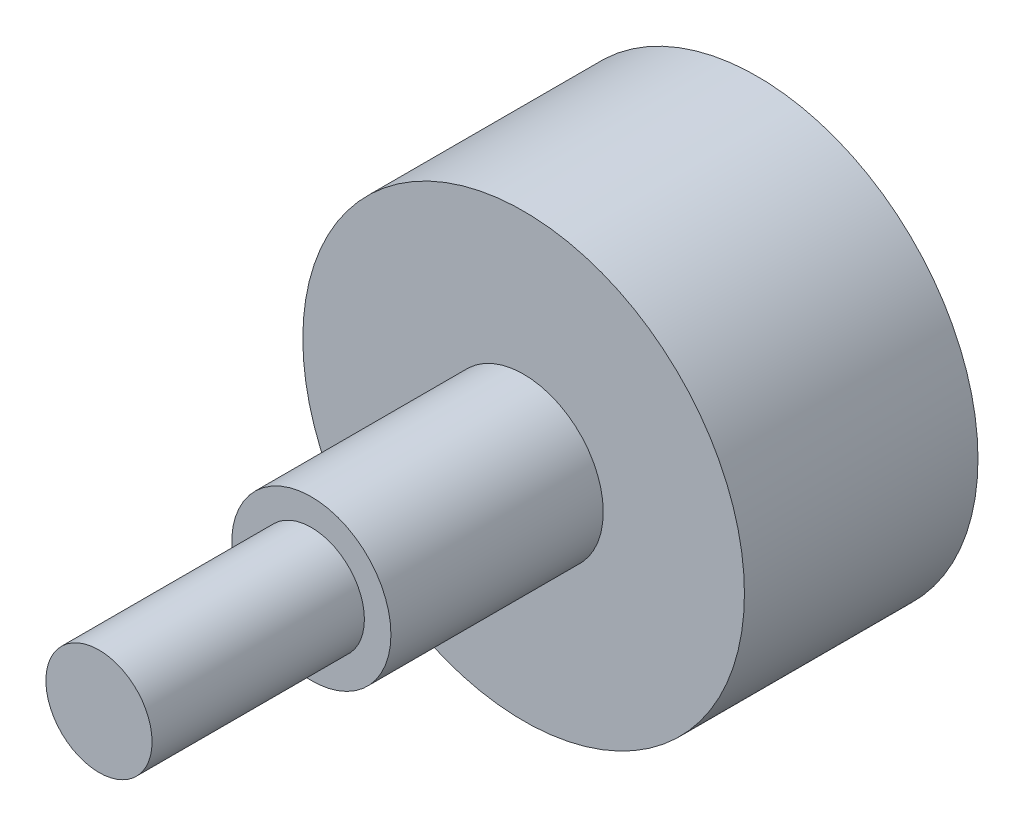
from build123d import *

# Parameters (mm, degrees)
SKETCH1_R      = 13.208
EXTRUDE1_DEPTH = 13.97
SKETCH2_R      = 4.7625
EXTRUDE2_DEPTH = 12.7
SKETCH3_R      = 3.175
EXTRUDE3_DEPTH = 12.7


with BuildPart() as part:
    # Sketch1 → Extrude1 (new body)
    with BuildSketch(Plane.XY):
        Circle(SKETCH1_R)
    extrude(amount=EXTRUDE1_DEPTH)

    # Sketch2 → Extrude2 (add)
    with BuildSketch(Plane.XY.offset(13.97)):
        Circle(SKETCH2_R)
    extrude(amount=EXTRUDE2_DEPTH)

    # Sketch3 → Extrude3 (add)
    with BuildSketch(Plane.XY.offset(26.67)):
        Circle(SKETCH3_R)
    extrude(amount=EXTRUDE3_DEPTH)


solid = part.part
